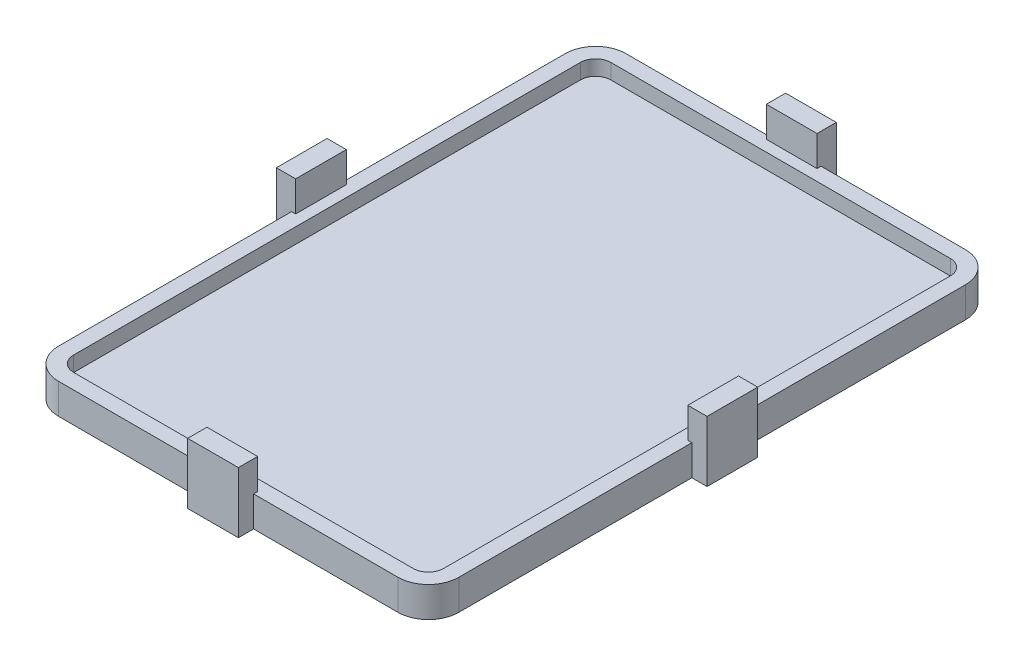
from build123d import *

# Parameters (mm, degrees)
SKETCH1_W           = 39.5
SKETCH1_H           = 56
BOSS_EXTRUDE1_DEPTH = 3
FILLET1_R           = 3
SHELL1_T            = -1.5
SKETCH2_W           = 5
SKETCH2_H           = 3
BOSS_EXTRUDE2_DEPTH = 1.5
SKETCH3_W           = 1.9
SKETCH3_H           = 5
BOSS_EXTRUDE3_DEPTH = 3
SKETCH8_W           = 5
SKETCH8_H           = 3
BOSS_EXTRUDE5_DEPTH = 1.5
SKETCH9_W           = 5
SKETCH9_H           = 1.9
BOSS_EXTRUDE6_DEPTH = 3


with BuildPart() as part:
    # Sketch1 → Boss-Extrude1 (new body)
    with BuildSketch(Plane(origin=(0, 0, 0), x_dir=(1, 0, 0), z_dir=(0, 1, 0))):
        with Locations((19.75, 28)):
            Rectangle(SKETCH1_W, SKETCH1_H)
    extrude(amount=BOSS_EXTRUDE1_DEPTH)

    # Fillet1
    fillet1_edges = [part.edges().sort_by_distance(p)[0] for p in [
        (0, 1.5, -56),
        (39.5, 1.5, -56),
        (39.5, 1.5, 0),
        (0, 1.5, 0),
    ]]
    fillet(fillet1_edges, radius=FILLET1_R)

    # Shell1
    shell1_openings = [part.faces().sort_by_distance(p)[0] for p in [
        (19.75, 3, -28),
    ]]
    offset(amount=SHELL1_T, openings=shell1_openings, kind=Kind.INTERSECTION)

    # Sketch2 → Boss-Extrude2 (add)
    with BuildSketch(Plane.ZY):
        with Locations((-28.5, 1.5)):
            Rectangle(SKETCH2_W, SKETCH2_H)
    boss_extrude2 = extrude(amount=BOSS_EXTRUDE2_DEPTH)

    # Sketch3 → Boss-Extrude3 (add)
    with BuildSketch(Plane(origin=(0, 3, 0), x_dir=(1, 0, 0), z_dir=(0, 1, 0))):
        with Locations((-0.55, 28.5)):
            Rectangle(SKETCH3_W, SKETCH3_H)
    boss_extrude3 = extrude(amount=BOSS_EXTRUDE3_DEPTH)

    # Sketch8 → Boss-Extrude5 (add)
    with BuildSketch(Plane.XY):
        with Locations((19.75, 1.5)):
            Rectangle(SKETCH8_W, SKETCH8_H)
    boss_extrude5 = extrude(amount=BOSS_EXTRUDE5_DEPTH)

    # Sketch9 → Boss-Extrude6 (add)
    with BuildSketch(Plane(origin=(0, 3, 0), x_dir=(1, 0, 0), z_dir=(0, 1, 0))):
        with Locations((19.75, -0.55)):
            Rectangle(SKETCH9_W, SKETCH9_H)
    boss_extrude6 = extrude(amount=BOSS_EXTRUDE6_DEPTH)

    # Mirror3: Boss-Extrude2, Boss-Extrude3 across plane
    add(boss_extrude2.mirror(Plane(origin=(19.75, 0, 0), x_dir=(0, 0, 1), z_dir=(1, 0, 0))))
    add(boss_extrude3.mirror(Plane(origin=(19.75, 0, 0), x_dir=(0, 0, 1), z_dir=(1, 0, 0))))

    # Mirror4: Boss-Extrude5, Boss-Extrude6 across plane
    add(boss_extrude5.mirror(Plane(origin=(0, 0, -28), x_dir=(1, 0, 0), z_dir=(0, 0, -1))))
    add(boss_extrude6.mirror(Plane(origin=(0, 0, -28), x_dir=(1, 0, 0), z_dir=(0, 0, -1))))


solid = part.part
